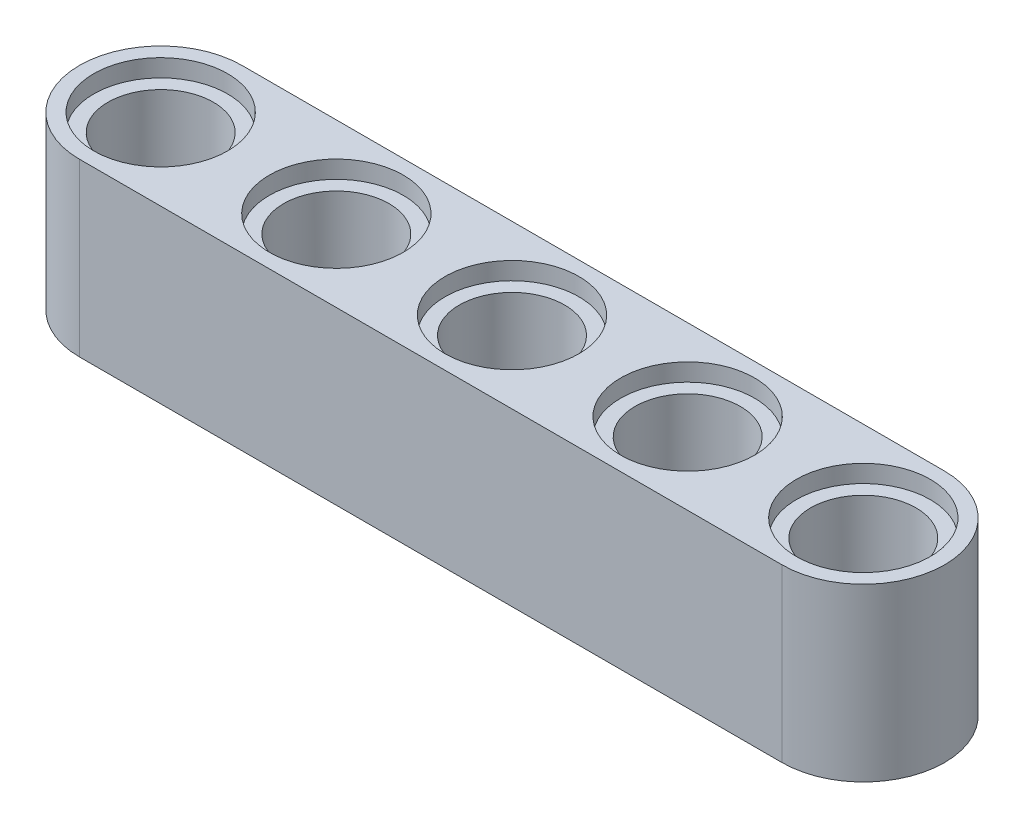
from build123d import *

# Parameters (mm, degrees)
BOSS_EXTRUDE3_DEPTH = 7.8
SKETCH2_R           = 2.4
CUT_EXTRUDE6_DEPTH  = 7.8
SKETCH3_R           = 3.05
CUT_EXTRUDE7_DEPTH  = 0.8
SKETCH4_R           = 3.05
CUT_EXTRUDE8_DEPTH  = 0.8


with BuildPart() as part:
    # Sketch1 → Boss-Extrude3 (new body)
    with BuildSketch(Plane(origin=(0, 0, 0), x_dir=(1, 0, 0), z_dir=(0, 1, 0))):
        with BuildLine():
            Line((-16, -3.7), (16, -3.7))
            ThreePointArc((16, -3.7), (19.7, 0), (16, 3.7))
            Line((16, 3.7), (-16, 3.7))
            ThreePointArc((-16, 3.7), (-19.7, 0), (-16, -3.7))
        make_face()
    extrude(amount=BOSS_EXTRUDE3_DEPTH)

    # Sketch2 → Cut-Extrude6 (cut)
    with BuildSketch(Plane(origin=(0, 7.8, 0), x_dir=(1, 0, 0), z_dir=(0, 1, 0))):
        Circle(SKETCH2_R)
        with Locations((8, 0)):
            Circle(SKETCH2_R)
        with Locations((16, 0)):
            Circle(SKETCH2_R)
        with Locations((-16, 0)):
            Circle(SKETCH2_R)
        with Locations((-8, 0)):
            Circle(SKETCH2_R)
    extrude(amount=-CUT_EXTRUDE6_DEPTH, mode=Mode.SUBTRACT)

    # Sketch3 → Cut-Extrude7 (cut)
    with BuildSketch(Plane(origin=(0, 7.8, 0), x_dir=(1, 0, 0), z_dir=(0, 1, 0))):
        Circle(SKETCH3_R)
        with Locations((8, 0)):
            Circle(SKETCH3_R)
        with Locations((16, 0)):
            Circle(SKETCH3_R)
        with Locations((-16, 0)):
            Circle(SKETCH3_R)
        with Locations((-8, 0)):
            Circle(SKETCH3_R)
    extrude(amount=-CUT_EXTRUDE7_DEPTH, mode=Mode.SUBTRACT)

    # Sketch4 → Cut-Extrude8 (cut)
    with BuildSketch(Plane.XZ):
        Circle(SKETCH4_R)
        with Locations((8, 0)):
            Circle(SKETCH4_R)
        with Locations((16, 0)):
            Circle(SKETCH4_R)
        with Locations((-16, 0)):
            Circle(SKETCH4_R)
        with Locations((-8, 0)):
            Circle(SKETCH4_R)
    extrude(amount=-CUT_EXTRUDE8_DEPTH, mode=Mode.SUBTRACT)


solid = part.part
